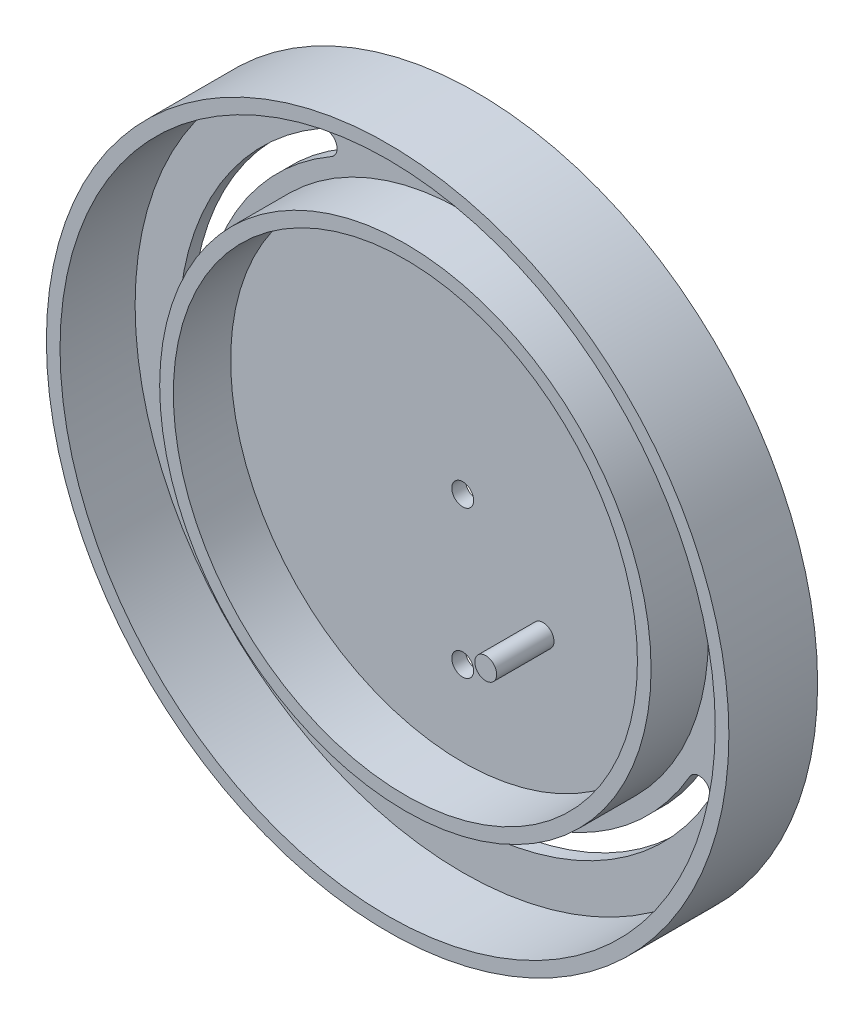
from build123d import *

# Parameters (mm, degrees)
BOSS_EXTRUDE1_DEPTH      = 1.25
BOSS_EXTRUDE1_DEPTH_BACK = 1.25
SKETCH1_R                = 60
SKETCH1_R_2              = 2
SKETCH1_3_R              = 45
SKETCH1_3_R_2            = 42.5
SKETCH1_3_R_3            = 2
BOSS_EXTRUDE2_DEPTH      = 11.75
BOSS_EXTRUDE3_DEPTH      = 15
BOSS_EXTRUDE3_DEPTH_BACK = 1.25
SKETCH1_4_R              = 62.5
SKETCH1_4_R_2            = 60


with BuildPart() as part:
    # Sketch1 → Boss-Extrude1 (new, two sides: drawn at the far end of the back side and taken through both)
    with BuildSketch(Plane.XY.offset(-BOSS_EXTRUDE1_DEPTH_BACK)):
        Circle(SKETCH1_R)
        with BuildLine():
            ThreePointArc((45.033320997, -26), (13.458590345, -50.228142967), (-26, -45.033320997))
            ThreePointArc((-26, -45.033320997), (-26.732050808, -42.301270189), (-24, -41.569219382))
            ThreePointArc((-24, -41.569219382), (12.423314165, -46.364439662), (41.569219382, -24))
            ThreePointArc((41.569219382, -24), (44.301270189, -23.267949192), (45.033320997, -26))
        make_face(mode=Mode.SUBTRACT)
        with BuildLine():
            ThreePointArc((-45.033320997, -26), (-50.228142967, 13.458590345), (-26, 45.033320997))
            ThreePointArc((-26, 45.033320997), (-23.267949192, 44.301270189), (-24, 41.569219382))
            ThreePointArc((-24, 41.569219382), (-46.364439662, 12.423314165), (-41.569219382, -24))
            ThreePointArc((-41.569219382, -24), (-42.301270189, -26.732050808), (-45.033320997, -26))
        make_face(mode=Mode.SUBTRACT)
        with BuildLine():
            ThreePointArc((0, 52), (36.769552622, 36.769552622), (52, 0))
            ThreePointArc((52, 0), (50, -2), (48, 0))
            ThreePointArc((48, 0), (33.941125497, 33.941125497), (0, 48))
            ThreePointArc((0, 48), (-2, 50), (0, 52))
        make_face(mode=Mode.SUBTRACT)
        Circle(SKETCH1_R_2, mode=Mode.SUBTRACT)
        with Locations((0, -27)):
            Circle(SKETCH1_R_2, mode=Mode.SUBTRACT)
    extrude(amount=BOSS_EXTRUDE1_DEPTH + BOSS_EXTRUDE1_DEPTH_BACK)

    # Sketch1_3 → Boss-Extrude2 (add)
    # profile 1 of 2: a face of its own
    with BuildSketch(Plane.XY):
        Circle(SKETCH1_3_R)
        Circle(SKETCH1_3_R_2, mode=Mode.SUBTRACT)
    # profile 2 of 2: a face of its own
    with BuildSketch(Plane.XY):
        with Locations((14.715815051, -14.981481481)):
            Circle(SKETCH1_3_R_3)
    extrude(amount=BOSS_EXTRUDE2_DEPTH)

    # Sketch1_4 → Boss-Extrude3 (add, two sides: drawn at the far end of the back side and taken through both)
    with BuildSketch(Plane.XY.offset(-BOSS_EXTRUDE3_DEPTH_BACK)):
        Circle(SKETCH1_4_R)
        Circle(SKETCH1_4_R_2, mode=Mode.SUBTRACT)
    extrude(amount=BOSS_EXTRUDE3_DEPTH + BOSS_EXTRUDE3_DEPTH_BACK)


solid = part.part
